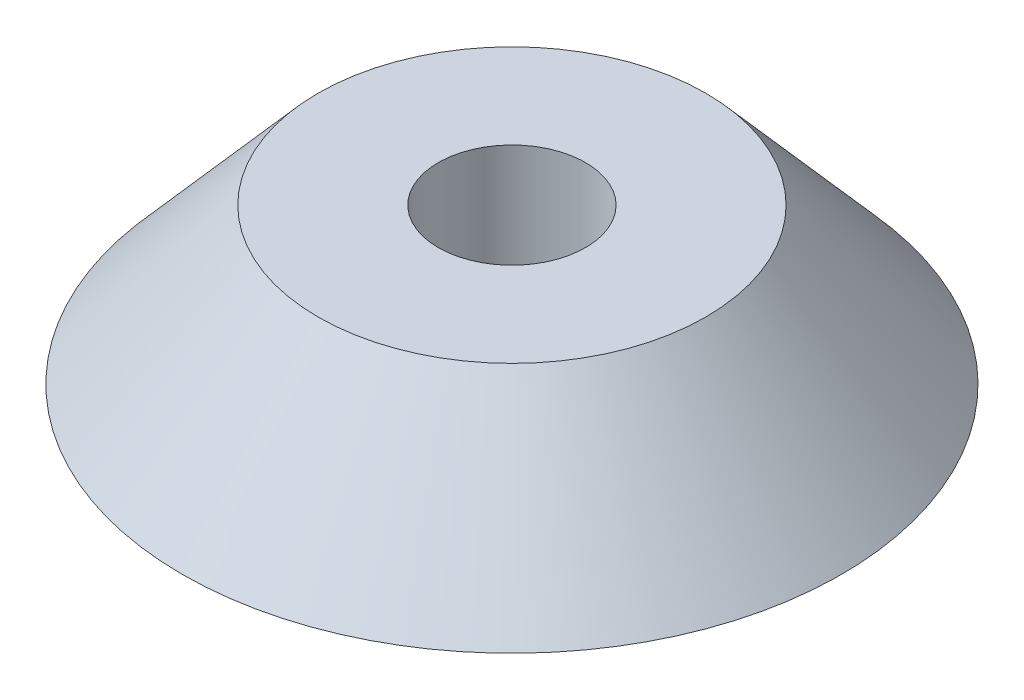
from build123d import *

# Parameters (mm, degrees)
SKETCH1_R          = 10.795
SKETCH2_R          = 6.35
SKETCH1_3_R        = 2.413
CUT_EXTRUDE1_DEPTH = 17.089451679


with BuildPart() as part:
    # Sketch1 → Loft1 section 0
    with BuildSketch(Plane(origin=(0, 0, 0), x_dir=(1, 0, 0), z_dir=(0, 1, 0))):
        Circle(SKETCH1_R)
    # Sketch2 → Loft1 section 1
    with BuildSketch(Plane(origin=(0, 5.08, 0), x_dir=(1, 0, 0), z_dir=(0, 1, 0))):
        Circle(SKETCH2_R)
    loft()

    # Sketch1_3 → Cut-Extrude1 (cut, through all)
    with BuildSketch(Plane(origin=(0, 0, 0), x_dir=(1, 0, 0), z_dir=(0, 1, 0))):
        Circle(SKETCH1_3_R)
    extrude(amount=CUT_EXTRUDE1_DEPTH, mode=Mode.SUBTRACT)


solid = part.part
